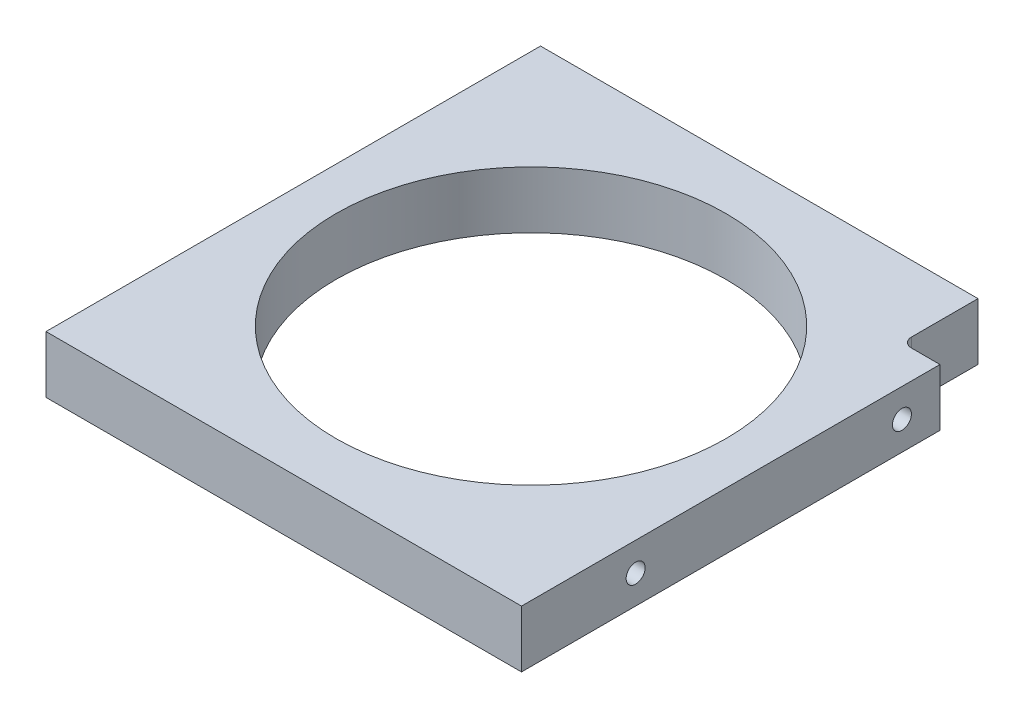
from build123d import *

# Parameters (mm, degrees)
SKETCH1_W           = 79.375
SKETCH1_H           = 82.55
SKETCH1_R           = 32.54375
BOSS_EXTRUDE1_DEPTH = 4.7625
SKETCH2_R           = 1.5875
CUT_EXTRUDE1_DEPTH  = 12.7
SKETCH3_W           = 12.7
SKETCH3_H           = 6.35
CUT_EXTRUDE2_DEPTH  = 10.525
FILLET1_R           = 1.5875


with BuildPart() as part:
    # Sketch1 → Boss-Extrude1 (new body, symmetric)
    with BuildSketch(Plane(origin=(0, 0, 0), x_dir=(1, 0, 0), z_dir=(0, 1, 0))):
        Rectangle(SKETCH1_W, SKETCH1_H)
        Circle(SKETCH1_R, mode=Mode.SUBTRACT)
    extrude(amount=BOSS_EXTRUDE1_DEPTH, both=True)

    # Sketch2 → Cut-Extrude1 (cut)
    with BuildSketch(Plane.ZY.offset(39.6875)):
        with Locations((-22.225, 0)):
            Circle(SKETCH2_R)
        with Locations((22.225, 0)):
            Circle(SKETCH2_R)
    cut_extrude1 = extrude(amount=-CUT_EXTRUDE1_DEPTH, mode=Mode.SUBTRACT)

    # Mirror1: Cut-Extrude1 across plane
    add(cut_extrude1.mirror(Plane(origin=(0, 0, 0), x_dir=(0, 0, 1), z_dir=(1, 0, 0))), mode=Mode.SUBTRACT)

    # Sketch3 → Cut-Extrude2 (cut, through all)
    with BuildSketch(Plane(origin=(34.925, 4.7625, 0), x_dir=(0, 0, -1), z_dir=(0, -1, 0))):
        with Locations((34.925, 1.5875)):
            Rectangle(SKETCH3_W, SKETCH3_H)
    extrude(amount=CUT_EXTRUDE2_DEPTH, mode=Mode.SUBTRACT)

    # Fillet1
    fillet1_edges = [part.edges().sort_by_distance(p)[0] for p in [
        (33.3375, 0, -28.575),
    ]]
    fillet(fillet1_edges, radius=FILLET1_R)


solid = part.part
